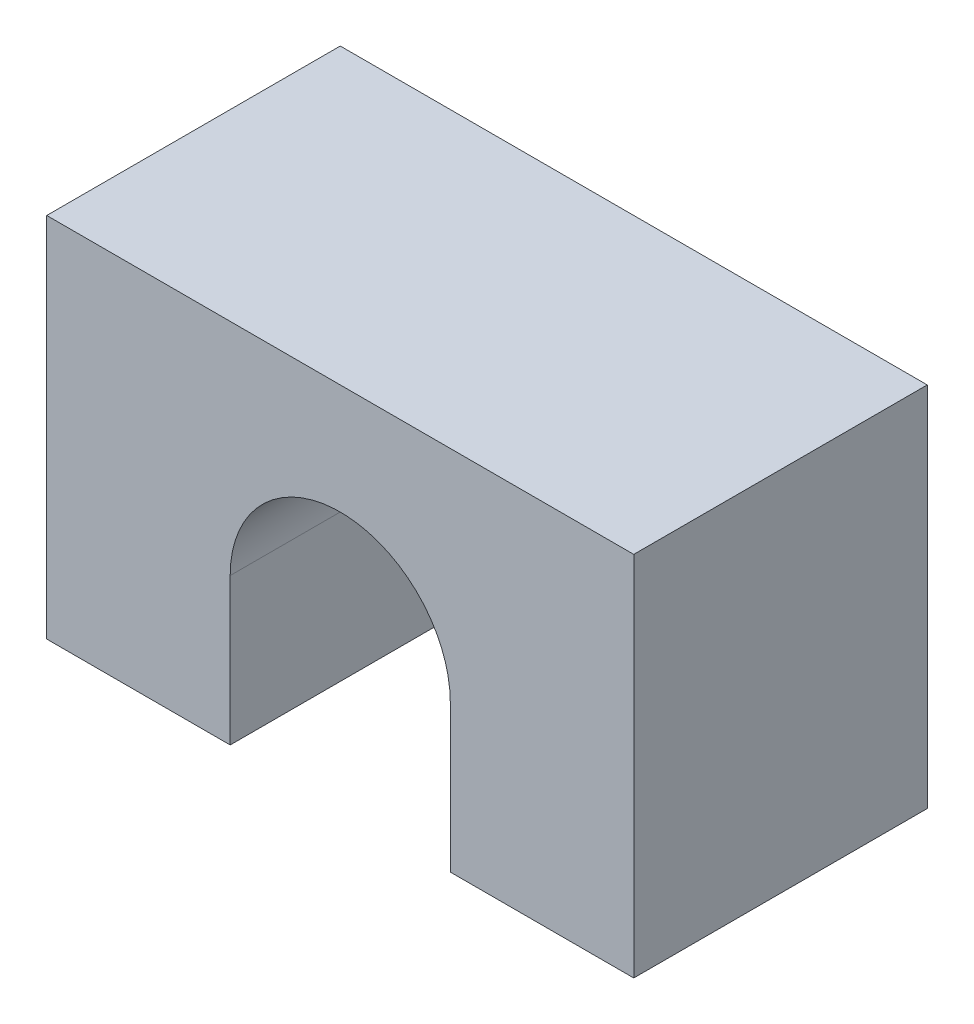
from build123d import *

# Parameters (mm, degrees)
BOSS_EXTRUDE1_DEPTH = 8


with BuildPart() as part:
    # Sketch3 → Boss-Extrude1 (new body)
    with BuildSketch(Plane.XY):
        with BuildLine():
            Line((-3, 0), (-3, -4))
            Line((-3, -4), (-8, -4))
            Line((-8, -4), (-8, 6))
            Line((-8, 6), (8, 6))
            Line((8, 6), (8, -4))
            Line((8, -4), (3, -4))
            Line((3, -4), (3, 0))
            ThreePointArc((3, 0), (0, 3), (-3, 0))
        make_face()
    extrude(amount=BOSS_EXTRUDE1_DEPTH)


solid = part.part
